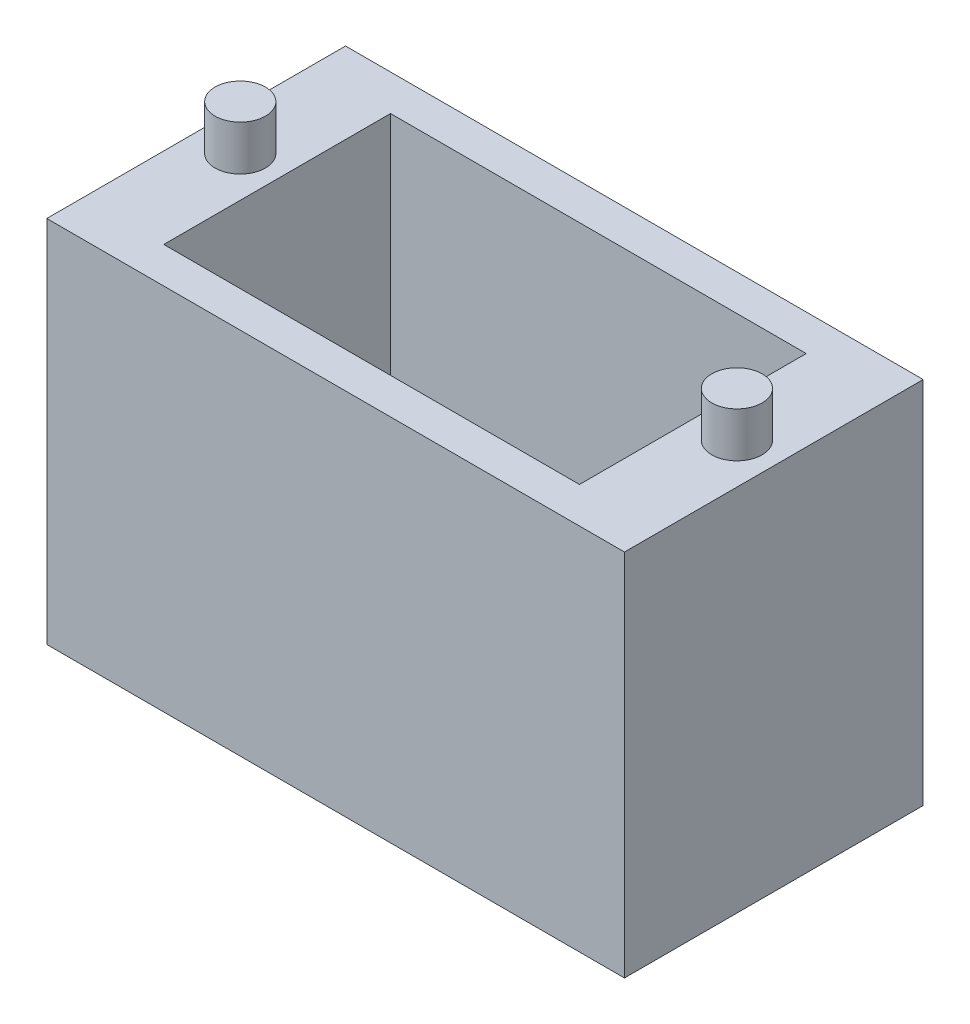
from build123d import *

# Parameters (mm, degrees)
EXTRUDE_2_DEPTH          = 12.2
SKETCH_5_W               = 3
SKETCH_5_H               = 8.5
CUT_EXTRUDE_1_DEPTH      = 22.5
SKETCH_6_R               = 1.4
EXTRUDE_3_DEPTH          = 2.5
SKETCH_7_W               = 12.2
SKETCH_7_H               = 1
CUT_EXTRUDE_2_DEPTH      = 1
CUT_EXTRUDE_2_DEPTH_BACK = 32.1
EXTRUDE_4_DEPTH          = 0.2
EXTRUDE_5_DEPTH          = 0.2
SKETCH_10_W              = 32.1
SKETCH_10_H              = 20.5
EXTRUDE_6_DEPTH          = 2
SKETCH_11_W              = 32.1
SKETCH_11_H              = 20.5
EXTRUDE_7_DEPTH          = 2


with BuildPart() as part:
    # 草图4 → 凸台-拉伸2 (new body)
    with BuildSketch(Plane.XY):
        Polygon((-11.55, 0), (11.55, 0), (11.55, 17), (16.05, 17), (16.05, -4.5), (-16.05, -4.5), (-16.05, 17), (-11.55, 17), align=None)
    extrude(amount=EXTRUDE_2_DEPTH)

    # 草图5 → 切除-拉伸1 (cut, through all)
    with BuildSketch(Plane.XZ.offset(4.5)):
        with Locations((-10.05, 4.25)):
            Rectangle(SKETCH_5_W, SKETCH_5_H)
    extrude(amount=-CUT_EXTRUDE_1_DEPTH, mode=Mode.SUBTRACT)

    # 草图6 → 凸台-拉伸3 (add)
    with BuildSketch(Plane(origin=(0, 17, 0), x_dir=(1, 0, 0), z_dir=(0, 1, 0))):
        with Locations((13.8, -6.1)):
            Circle(SKETCH_6_R)
        with Locations((-13.8, -6.1)):
            Circle(SKETCH_6_R)
    extrude(amount=EXTRUDE_3_DEPTH)

    # 草图7 → 切除-拉伸2 (cut, two sides)
    with BuildSketch(Plane(origin=(16.05, 0, 0), x_dir=(0, 0, -1), z_dir=(1, 0, 0))) as cut_extrude_2_sk:
        with Locations((-6.1, -4)):
            Rectangle(SKETCH_7_W, SKETCH_7_H)
    extrude(amount=CUT_EXTRUDE_2_DEPTH, mode=Mode.SUBTRACT)
    extrude(cut_extrude_2_sk.sketch, amount=-CUT_EXTRUDE_2_DEPTH_BACK, mode=Mode.SUBTRACT)

    # 草图8 → 凸台-拉伸4 (add)
    with BuildSketch(Plane.XY.offset(12.2)):
        Polygon((-11.55, 17), (-16.05, 17), (-16.05, -3.5), (16.05, -3.5), (16.05, 17), (11.55, 17), (11.55, 0), (-11.55, 0), align=None)
    extrude(amount=EXTRUDE_4_DEPTH)

    # 草图9 → 凸台-拉伸5 (add)
    with BuildSketch(Plane.XY.offset(12.4)):
        Polygon((-11.55, 0), (-11.55, 17), (-16.05, 17), (-16.05, -3.5), (16.05, -3.5), (16.05, 17), (11.55, 17), (11.55, 0), align=None)
    extrude(amount=EXTRUDE_5_DEPTH)

    # 草图10 → 凸台-拉伸6 (add)
    with BuildSketch(Plane.XY.offset(12.6)):
        with Locations((0, 6.75)):
            Rectangle(SKETCH_10_W, SKETCH_10_H)
    extrude(amount=EXTRUDE_6_DEPTH)

    # 草图11 → 凸台-拉伸7 (add)
    with BuildSketch(Plane(origin=(0, 0, 0), x_dir=(-1, 0, 0), z_dir=(0, 0, -1))):
        with Locations((0, 6.75)):
            Rectangle(SKETCH_11_W, SKETCH_11_H)
    extrude(amount=EXTRUDE_7_DEPTH)


solid = part.part
